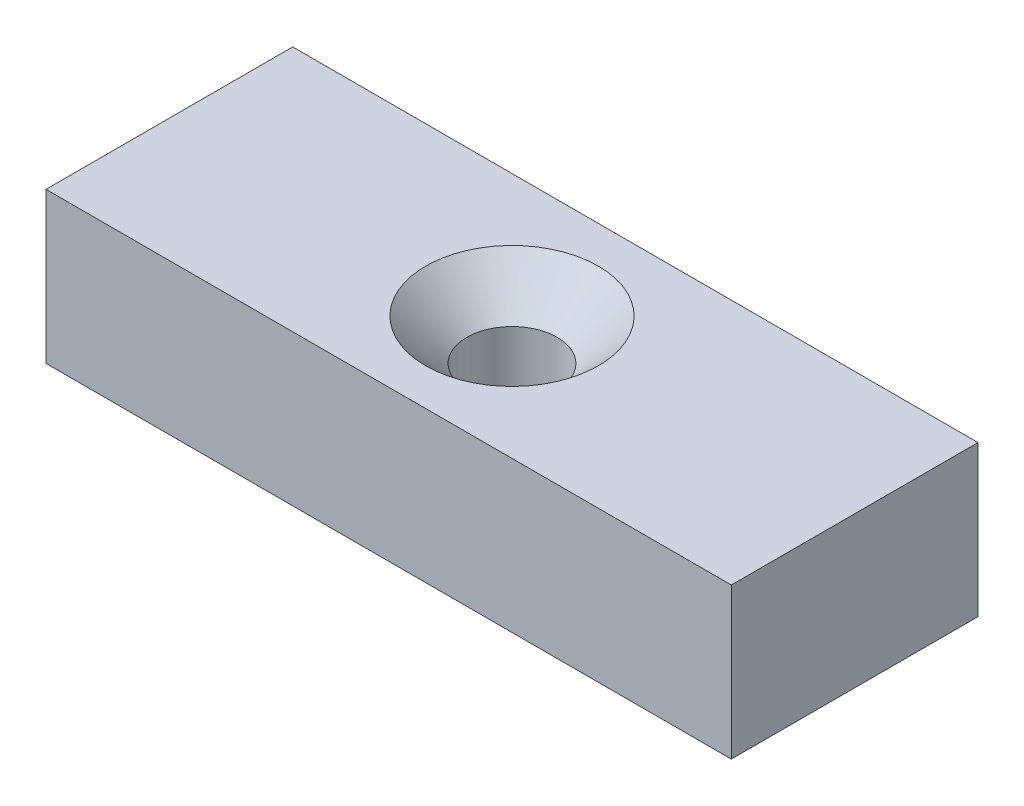
from build123d import *

# Parameters (mm, degrees)
BOSS_EXTRUDE1_DEPTH                                 = 11
SKETCH2_W                                           = 10.92366107
SKETCH2_H                                           = 18
SKETCH2_W_2                                         = 14.331152634
CUT_EXTRUDE1_DEPTH                                  = 12
CSK_FOR_M6_COUNTERSUNK_FLAT_HEAD_SCREW1_D           = 6.6
CSK_FOR_M6_COUNTERSUNK_FLAT_HEAD_SCREW1_CSINK_D     = 12.6
CSK_FOR_M6_COUNTERSUNK_FLAT_HEAD_SCREW1_CSINK_ANGLE = 90


with BuildPart() as part:
    # Sketch1 → Boss-Extrude1 (new body)
    with BuildSketch(Plane(origin=(0, 0, 0), x_dir=(1, 0, 0), z_dir=(0, 1, 0))):
        with BuildLine():
            Line((0, 9), (50, 9))
            ThreePointArc((50, 9), (59, 0), (50, -9))
            Line((50, -9), (0, -9))
            ThreePointArc((0, -9), (-9, 0), (0, 9))
        make_face()
    extrude(amount=BOSS_EXTRUDE1_DEPTH)

    # Sketch2 → Cut-Extrude1 (cut, through all)
    with BuildSketch(Plane(origin=(0, 11, 0), x_dir=(1, 0, 0), z_dir=(0, 1, 0))):
        with Locations((-5.461830535, 0)):
            Rectangle(SKETCH2_W, SKETCH2_H)
        with Locations((57.165576317, 0)):
            Rectangle(SKETCH2_W_2, SKETCH2_H)
    extrude(amount=-CUT_EXTRUDE1_DEPTH, mode=Mode.SUBTRACT)

    # CSK for M6 Countersunk Flat Head Screw1 (through all)
    with Locations(Plane(origin=(0, 11, 0), x_dir=(1, 0, 0), z_dir=(0, 1, 0))):
        with Locations((25, 0)):
            CounterSinkHole(CSK_FOR_M6_COUNTERSUNK_FLAT_HEAD_SCREW1_D / 2, CSK_FOR_M6_COUNTERSUNK_FLAT_HEAD_SCREW1_CSINK_D / 2, counter_sink_angle=CSK_FOR_M6_COUNTERSUNK_FLAT_HEAD_SCREW1_CSINK_ANGLE)


solid = part.part
